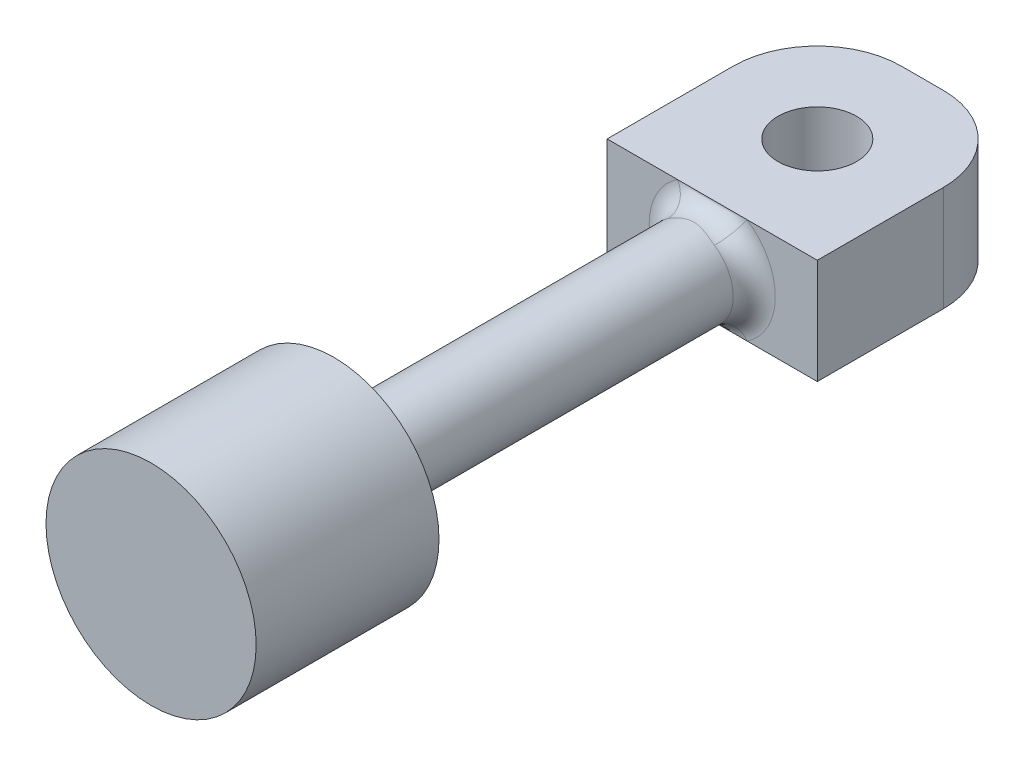
from build123d import *

# Parameters (mm, degrees)
SKETCH1_W                = 1
SKETCH1_H                = 9
SKETCH1_3_R              = 0.935
BOSS_EXTRUDE1_DEPTH      = 1.25
BOSS_EXTRUDE1_DEPTH_BACK = 1.25
FILLET1_R                = 0.5
FILLET2_R                = 0.5


with BuildPart() as part:
    # Sketch1 → Revolve1 (revolve)
    with BuildSketch(Plane(origin=(0, 0, 0), x_dir=(1, 0, 0), z_dir=(0, 1, 0))):
        with Locations((3, -4.5)):
            Rectangle(SKETCH1_W, SKETCH1_H)
    revolve(axis=Axis((2.5, 0, 0), (0, 0, -1)))

    # Sketch1_3 → Boss-Extrude1 (add, two sides)
    with BuildSketch(Plane(origin=(0, 0, 0), x_dir=(1, 0, 0), z_dir=(0, 1, 0))) as boss_extrude1_sk:
        with BuildLine():
            Line((0, 0), (5, 0))
            Line((5, 0), (5, 3))
            ThreePointArc((5, 3), (4.414213562, 4.414213562), (3, 5))
            Line((3, 5), (2, 5))
            ThreePointArc((2, 5), (0.585786438, 4.414213562), (0, 3))
            Line((0, 3), (0, 0))
        make_face()
        with Locations((2.5, 2.5)):
            Circle(SKETCH1_3_R, mode=Mode.SUBTRACT)
    extrude(amount=BOSS_EXTRUDE1_DEPTH)
    extrude(boss_extrude1_sk.sketch, amount=-BOSS_EXTRUDE1_DEPTH_BACK)

    # Fillet1
    fillet1_edges = [part.edges().sort_by_distance(p)[0] for p in [
        (1.5, 0, 0),
    ]]
    fillet(fillet1_edges, radius=FILLET1_R)

    # Sketch1_4 → Revolve2 (revolve)
    with BuildSketch(Plane(origin=(0, 0, 0), x_dir=(1, 0, 0), z_dir=(0, 1, 0))):
        Polygon((3.5, -9), (2.5, -9), (2.5, -13.35), (5, -13.35), (5, -9), align=None)
    revolve(axis=Axis((2.5, 0, 0), (0, 0, -1)))

    # Fillet2
    fillet2_edges = [part.edges().sort_by_distance(p)[0] for p in [
        (1.5, 0, 9),
    ]]
    fillet(fillet2_edges, radius=FILLET2_R)


solid = part.part
